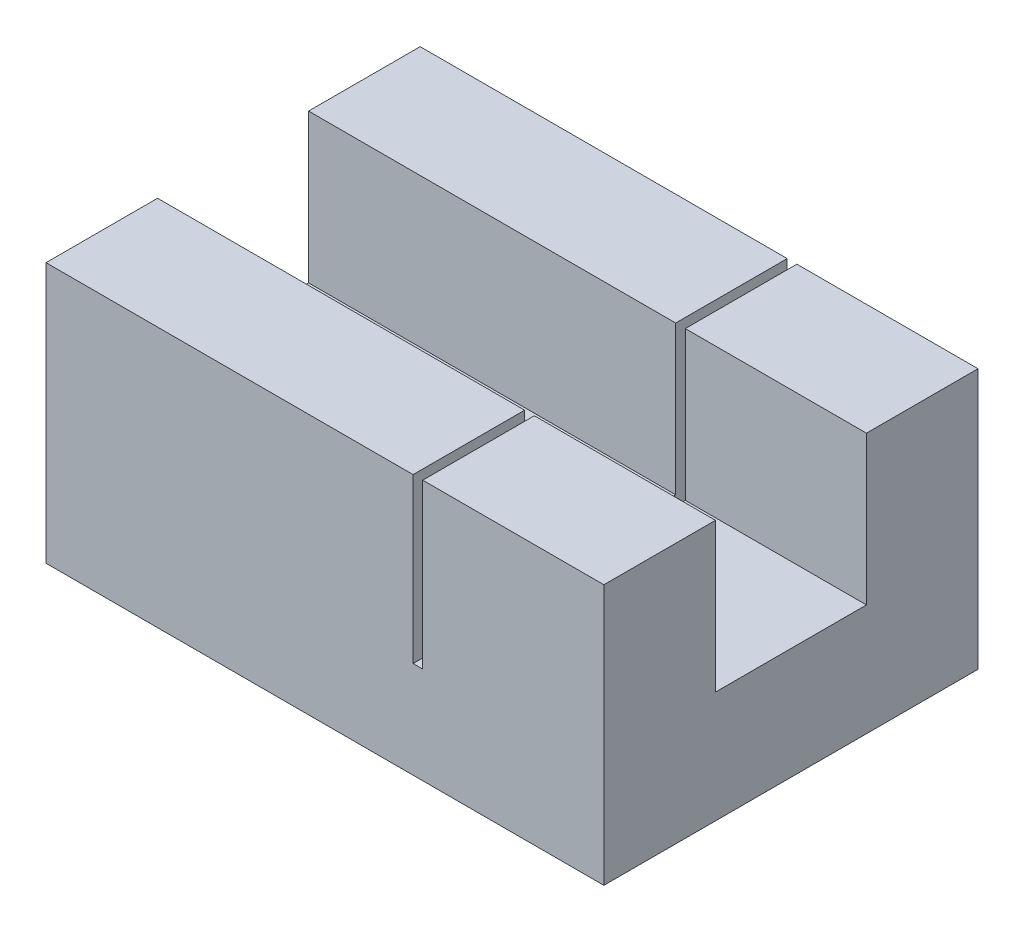
from build123d import *

# Parameters (mm, degrees)
SKETCH1_W           = 50
SKETCH1_H           = 20.3
BOSS_EXTRUDE1_DEPTH = 15
SKETCH2_W           = 50
SKETCH2_H           = 35
BOSS_EXTRUDE2_DEPTH = 15
SKETCH3_W           = 1.3
SKETCH3_H           = 50.3
CUT_EXTRUDE1_DEPTH  = 22
BOSS_EXTRUDE3_DEPTH = 25


with BuildPart() as part:
    # Sketch1 → Boss-Extrude1 (new body)
    with BuildSketch(Plane(origin=(0, 0, 0), x_dir=(1, 0, 0), z_dir=(0, 1, 0))):
        with Locations((25, 10.15)):
            Rectangle(SKETCH1_W, SKETCH1_H)
    extrude(amount=BOSS_EXTRUDE1_DEPTH)

    # Sketch2 → Boss-Extrude2 (add)
    with BuildSketch(Plane.XY):
        with Locations((25, 17.5)):
            Rectangle(SKETCH2_W, SKETCH2_H)
    boss_extrude2 = extrude(amount=BOSS_EXTRUDE2_DEPTH)

    # Mirror1: Boss-Extrude2 across plane
    add(boss_extrude2.mirror(Plane(origin=(0, 0, -10.15), x_dir=(1, 0, 0), z_dir=(0, 0, -1))))

    # Sketch3 → Cut-Extrude1 (cut)
    with BuildSketch(Plane(origin=(0, 35, 0), x_dir=(1, 0, 0), z_dir=(0, 1, 0))):
        with Locations((25, 10.15)):
            Rectangle(SKETCH3_W, SKETCH3_H)
    extrude(amount=-CUT_EXTRUDE1_DEPTH, mode=Mode.SUBTRACT)

    # Sketch4 → Boss-Extrude3 (add)
    with BuildSketch(Plane.ZY):
        Polygon((-35.3, 0), (15, 0), (15, 35), (0, 35), (0, 15), (-20.3, 15), (-20.3, 35), (-35.3, 35), align=None)
    extrude(amount=BOSS_EXTRUDE3_DEPTH)


solid = part.part
